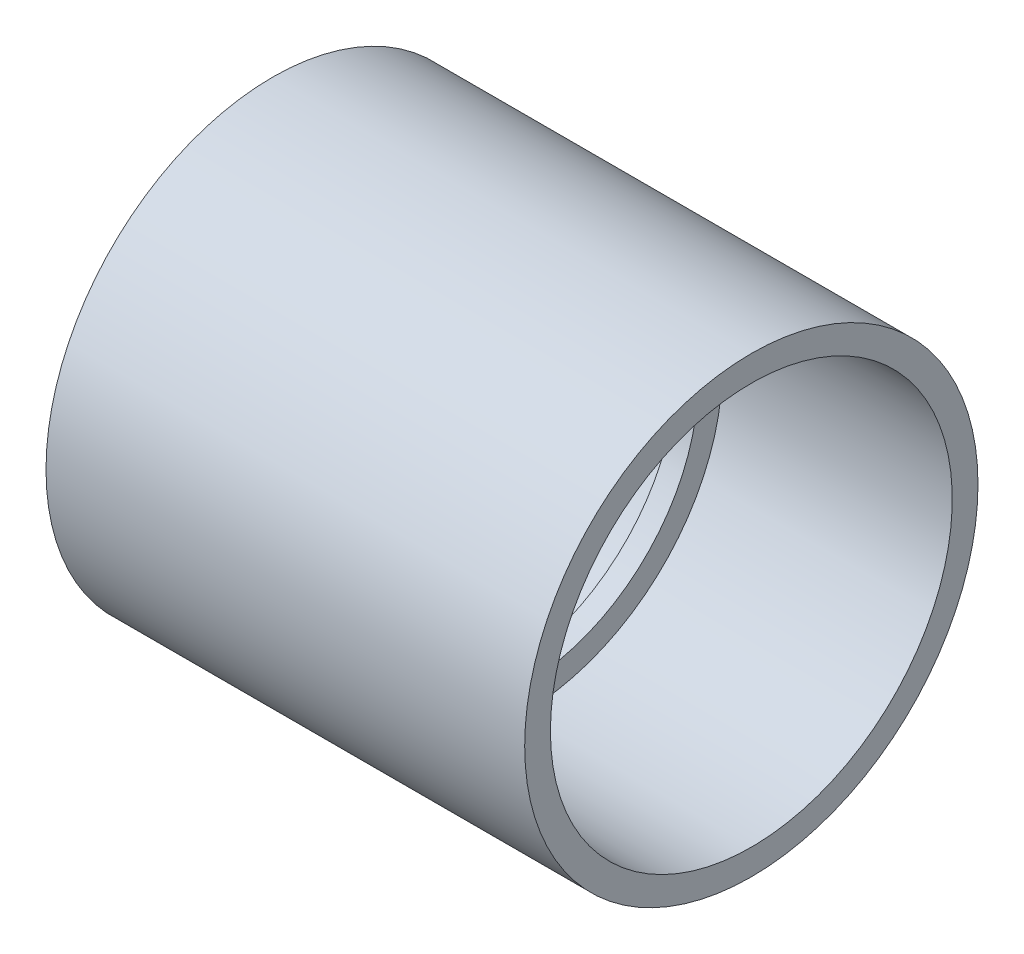
from build123d import *


with BuildPart() as part:
    # Sketch1 → Revolve1 (revolve)
    with BuildSketch(Plane.XY):
        Polygon((-2.3876, -38.9636), (2.3876, -38.9636), (2.3876, -44.3484), (53.1876, -44.6532), (53.1876, -50.3682), (-53.1876, -50.3682), (-53.1876, -44.6532), (-2.3876, -44.3484), align=None)
    revolve(axis=Axis((-53.1876, 0, 0), (1, 0, 0)))


solid = part.part
